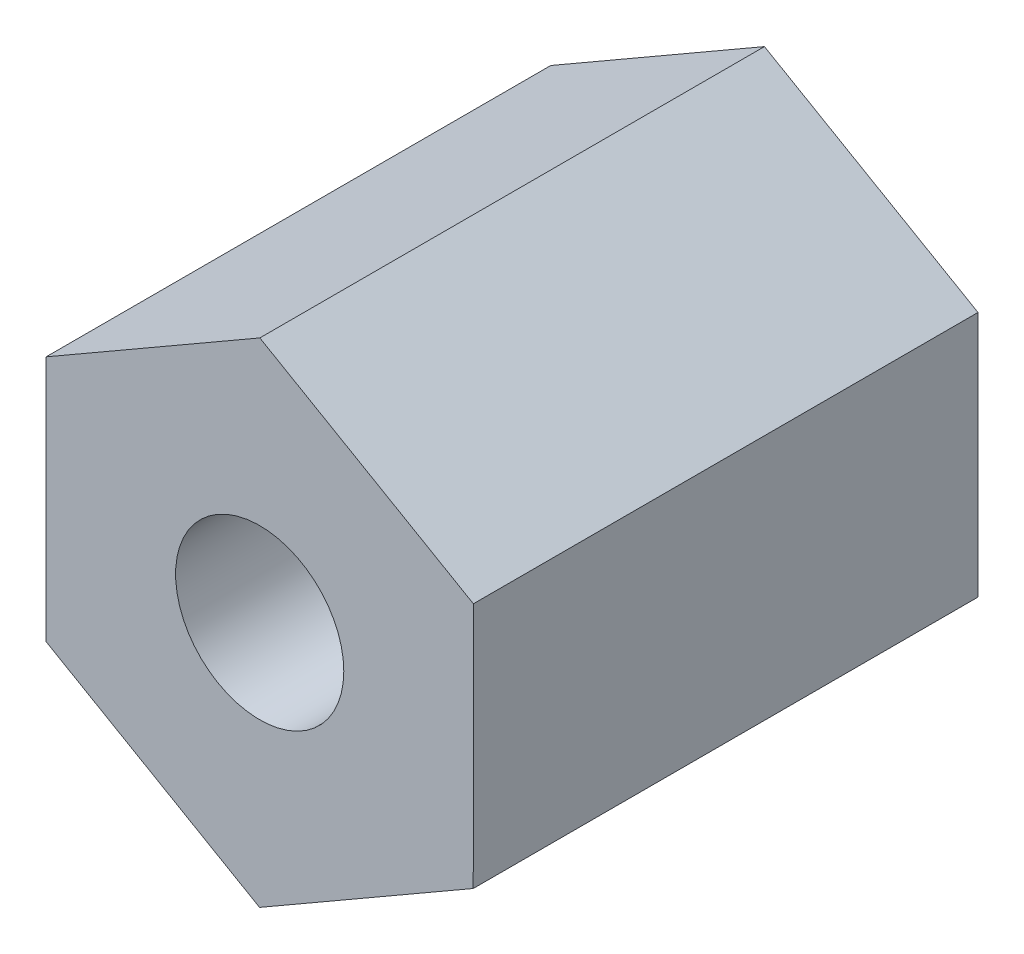
from build123d import *

# Parameters (mm, degrees)
CROQUIS1_R              = 2.5
SALIENTE_EXTRUIR1_DEPTH = 15


with BuildPart() as part:
    # Croquis1 → Saliente-Extruir1 (new body)
    with BuildSketch(Plane.XY):
        Polygon((6.347893759, -3.669819908), (6.352104147, 3.662527301), (0.004210389, 7.33234721), (-6.347893759, 3.669819908), (-6.352104147, -3.662527301), (-0.004210389, -7.33234721), align=None)
        Circle(CROQUIS1_R, mode=Mode.SUBTRACT)
    extrude(amount=SALIENTE_EXTRUIR1_DEPTH)


solid = part.part
